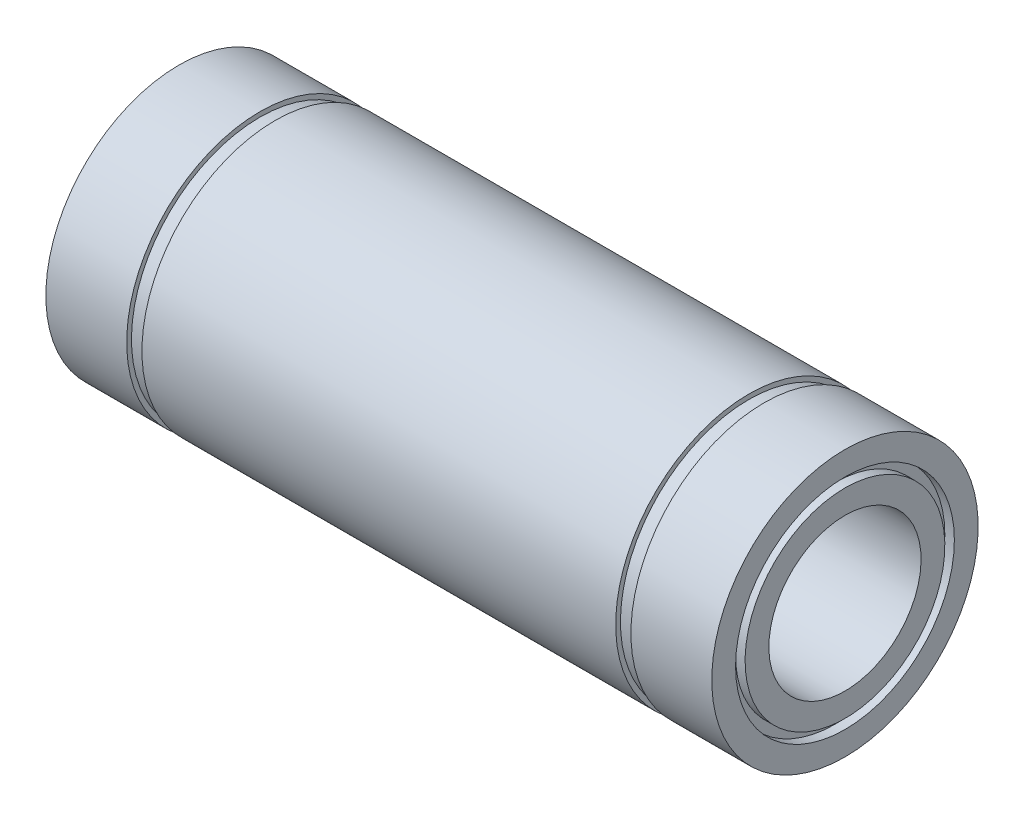
from build123d import *


with BuildPart() as part:
    # Esboço1 → Revolução1 (revolve)
    with BuildSketch(Plane.XY):
        Polygon((-35, 14), (-26.5, 14), (-26.5, 13.5), (-24.9, 13.5), (-24.9, 14), (24.9, 14), (24.9, 13.5), (26.5, 13.5), (26.5, 14), (35, 14), (35, 11.5), (34, 11.5), (34, 10.5), (35, 10.5), (35, 8), (-35, 8), (-35, 10.5), (-34, 10.5), (-34, 11.5), (-35, 11.5), align=None)
    revolve(axis=Axis((0, 0, 0), (-1, 0, 0)))


solid = part.part
